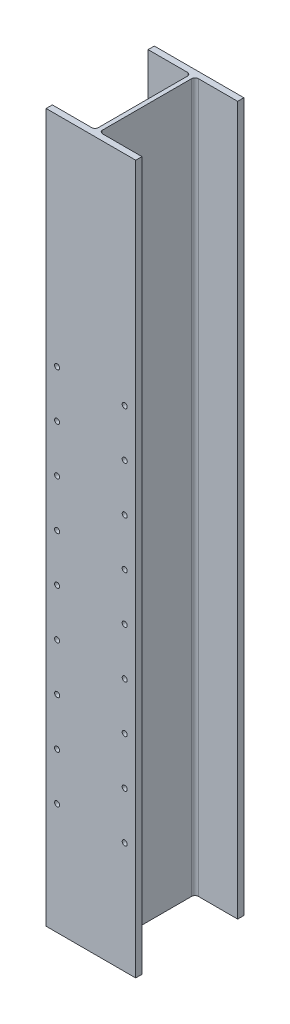
from build123d import *

# Parameters (mm, degrees)
BOSS_EXTRUDE1_DEPTH              = 665.1625
F_3_8_0_375_DIAMETER_HOLE1_D     = 9.525
F_3_8_0_375_DIAMETER_HOLE1_DEPTH = 11.684


with BuildPart() as part:
    # Sketch1 → Boss-Extrude1 (new body, symmetric)
    with BuildSketch(Plane(origin=(0, 0, 0), x_dir=(1, 0, 0), z_dir=(0, 1, 0))):
        with BuildLine():
            Line((-84.1375, 101.6), (84.1375, 101.6))
            Line((84.1375, 101.6), (84.1375, 89.916))
            Line((84.1375, 89.916), (10.31875, 89.916))
            ThreePointArc((10.31875, 89.916), (5.828621939, 88.056128061), (3.96875, 83.566))
            Line((3.96875, 83.566), (3.96875, -83.566))
            ThreePointArc((3.96875, -83.566), (5.828621939, -88.056128061), (10.31875, -89.916))
            Line((10.31875, -89.916), (84.1375, -89.916))
            Line((84.1375, -89.916), (84.1375, -101.6))
            Line((84.1375, -101.6), (-84.1375, -101.6))
            Line((-84.1375, -101.6), (-84.1375, -89.916))
            Line((-84.1375, -89.916), (-10.31875, -89.916))
            ThreePointArc((-10.31875, -89.916), (-5.828621939, -88.056128061), (-3.96875, -83.566))
            Line((-3.96875, -83.566), (-3.96875, 83.566))
            ThreePointArc((-3.96875, 83.566), (-5.828621939, 88.056128061), (-10.31875, 89.916))
            Line((-10.31875, 89.916), (-84.1375, 89.916))
            Line((-84.1375, 89.916), (-84.1375, 101.6))
        make_face()
    extrude(amount=BOSS_EXTRUDE1_DEPTH, both=True)

    # 3/8 (0.375) Diameter Hole1
    with Locations(Plane.XY.offset(101.6)):
        with Locations((-63.5, 255.5875), (63.5, 255.5875), (63.5, -455.6125), (63.5, -366.7125), (63.5, -277.8125), (63.5, -188.9125), (63.5, -100.0125), (63.5, -11.1125), (63.5, 77.7875), (-63.5, -455.6125), (-63.5, -366.7125), (-63.5, -277.8125), (-63.5, -188.9125), (-63.5, -100.0125), (-63.5, -11.1125), (-63.5, 77.7875), (-63.5, 166.6875), (63.5, 166.6875)):
            Hole(F_3_8_0_375_DIAMETER_HOLE1_D / 2, depth=F_3_8_0_375_DIAMETER_HOLE1_DEPTH)


solid = part.part
